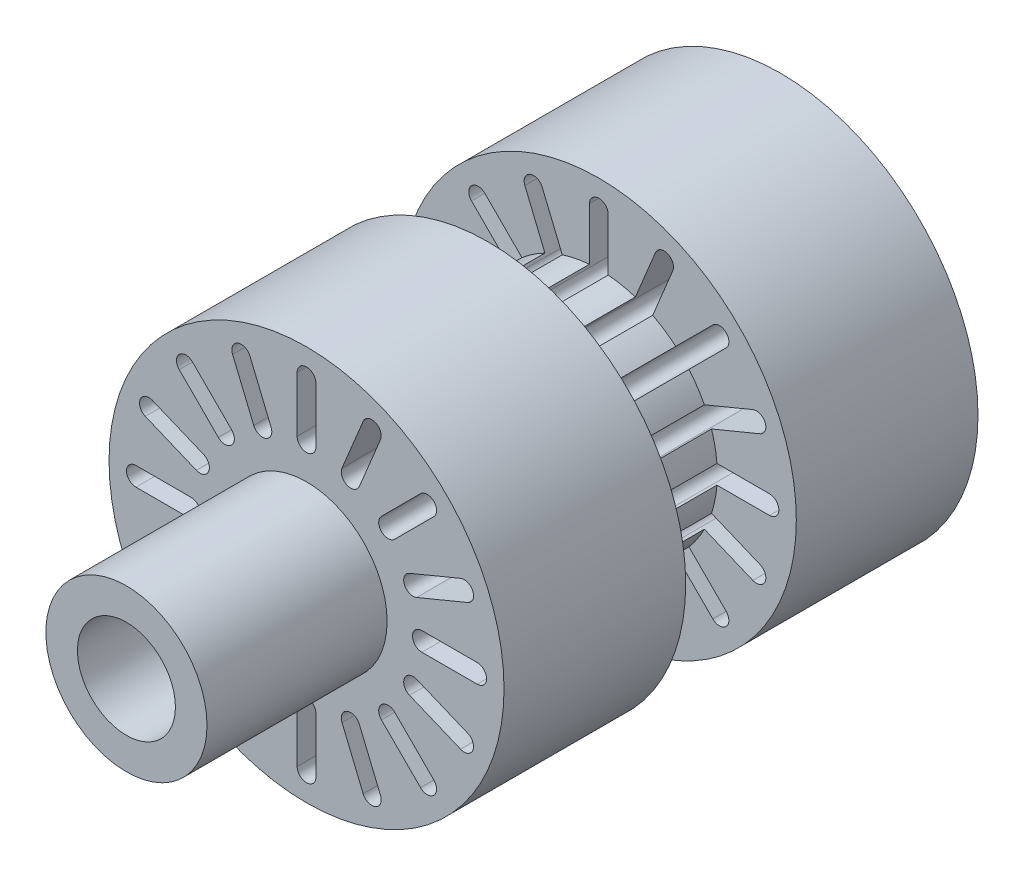
from build123d import *

# Parameters (mm, degrees)
CUT_EXTRUDE1_DEPTH = 86


with BuildPart() as part:
    # Sketch1 → Revolve1 (revolve)
    with BuildSketch(Plane(origin=(0, 0, 0), x_dir=(0, 0, -1), z_dir=(1, 0, 0))):
        Polygon((-15, 0), (15, 0), (3.6, 0), align=None)
        Polygon((-15, 5.1), (-15, 12.5), (-3.5, 12.5), (-3.5, 7.5), (3.5, 7.5), (3.5, 12.5), (15, 12.5), (15, 6), (3.6, 6), (3.6, 3.1), (-15, 3.1), (-26.4, 3.1), (-26.4, 5.1), align=None)
    revolve(axis=Axis((0, 0, 15), (0, 0, -1)))

    # Sketch2 → Cut-Extrude1 (cut)
    with BuildSketch(Plane(origin=(0, 0, -15), x_dir=(-1, 0, 0), z_dir=(0, 0, -1))):
        with BuildLine():
            Line((0.59414275, 10.8), (0.59414275, 7.3))
            ThreePointArc((0.59414275, 7.3), (0, 6.70585725), (-0.59414275, 7.3))
            Line((-0.59414275, 7.3), (-0.59414275, 10.8))
            ThreePointArc((-0.59414275, 10.8), (0, 11.39414275), (0.59414275, 10.8))
        make_face()
        with BuildLine():
            Line((3.584064744, 10.205267538), (2.24467273, 6.971689174))
            ThreePointArc((2.24467273, 6.971689174), (2.566220469, 6.195404261), (3.342505382, 6.516952001))
            Line((3.342505382, 6.516952001), (4.681897395, 9.750530364))
            ThreePointArc((4.681897395, 9.750530364), (4.360349656, 10.526815277), (3.584064744, 10.205267538))
        make_face()
        with BuildLine():
            Line((7.216630869, 8.056875604), (4.741757135, 5.58200187))
            ThreePointArc((4.741757135, 5.58200187), (4.741757135, 4.741757135), (5.58200187, 4.741757135))
            Line((5.58200187, 4.741757135), (8.056875604, 7.216630869))
            ThreePointArc((8.056875604, 7.216630869), (8.056875604, 8.056875604), (7.216630869, 8.056875604))
        make_face()
        with BuildLine():
            Line((9.750530364, 4.681897395), (6.516952001, 3.342505382))
            ThreePointArc((6.516952001, 3.342505382), (6.195404261, 2.566220469), (6.971689174, 2.24467273))
            Line((6.971689174, 2.24467273), (10.205267538, 3.584064744))
            ThreePointArc((10.205267538, 3.584064744), (10.526815277, 4.360349656), (9.750530364, 4.681897395))
        make_face()
        with BuildLine():
            Line((10.8, 0.59414275), (7.3, 0.59414275))
            ThreePointArc((7.3, 0.59414275), (6.70585725, 0), (7.3, -0.59414275))
            Line((7.3, -0.59414275), (10.8, -0.59414275))
            ThreePointArc((10.8, -0.59414275), (11.39414275, 0), (10.8, 0.59414275))
        make_face()
        with BuildLine():
            Line((10.205267538, -3.584064744), (6.971689174, -2.24467273))
            ThreePointArc((6.971689174, -2.24467273), (6.195404261, -2.566220469), (6.516952001, -3.342505382))
            Line((6.516952001, -3.342505382), (9.750530364, -4.681897395))
            ThreePointArc((9.750530364, -4.681897395), (10.526815277, -4.360349656), (10.205267538, -3.584064744))
        make_face()
        with BuildLine():
            Line((8.056875604, -7.216630869), (5.58200187, -4.741757135))
            ThreePointArc((5.58200187, -4.741757135), (4.741757135, -4.741757135), (4.741757135, -5.58200187))
            Line((4.741757135, -5.58200187), (7.216630869, -8.056875604))
            ThreePointArc((7.216630869, -8.056875604), (8.056875604, -8.056875604), (8.056875604, -7.216630869))
        make_face()
        with BuildLine():
            Line((4.681897395, -9.750530364), (3.342505382, -6.516952001))
            ThreePointArc((3.342505382, -6.516952001), (2.566220469, -6.195404261), (2.24467273, -6.971689174))
            Line((2.24467273, -6.971689174), (3.584064744, -10.205267538))
            ThreePointArc((3.584064744, -10.205267538), (4.360349656, -10.526815277), (4.681897395, -9.750530364))
        make_face()
        with BuildLine():
            Line((0.59414275, -10.8), (0.59414275, -7.3))
            ThreePointArc((0.59414275, -7.3), (0, -6.70585725), (-0.59414275, -7.3))
            Line((-0.59414275, -7.3), (-0.59414275, -10.8))
            ThreePointArc((-0.59414275, -10.8), (0, -11.39414275), (0.59414275, -10.8))
        make_face()
        with BuildLine():
            Line((-3.584064744, -10.205267538), (-2.24467273, -6.971689174))
            ThreePointArc((-2.24467273, -6.971689174), (-2.566220469, -6.195404261), (-3.342505382, -6.516952001))
            Line((-3.342505382, -6.516952001), (-4.681897395, -9.750530364))
            ThreePointArc((-4.681897395, -9.750530364), (-4.360349656, -10.526815277), (-3.584064744, -10.205267538))
        make_face()
        with BuildLine():
            Line((-7.216630869, -8.056875604), (-4.741757135, -5.58200187))
            ThreePointArc((-4.741757135, -5.58200187), (-4.741757135, -4.741757135), (-5.58200187, -4.741757135))
            Line((-5.58200187, -4.741757135), (-8.056875604, -7.216630869))
            ThreePointArc((-8.056875604, -7.216630869), (-8.056875604, -8.056875604), (-7.216630869, -8.056875604))
        make_face()
        with BuildLine():
            Line((-9.750530364, -4.681897395), (-6.516952001, -3.342505382))
            ThreePointArc((-6.516952001, -3.342505382), (-6.195404261, -2.566220469), (-6.971689174, -2.24467273))
            Line((-6.971689174, -2.24467273), (-10.205267538, -3.584064744))
            ThreePointArc((-10.205267538, -3.584064744), (-10.526815277, -4.360349656), (-9.750530364, -4.681897395))
        make_face()
        with BuildLine():
            Line((-10.8, -0.59414275), (-7.3, -0.59414275))
            ThreePointArc((-7.3, -0.59414275), (-6.70585725, 0), (-7.3, 0.59414275))
            Line((-7.3, 0.59414275), (-10.8, 0.59414275))
            ThreePointArc((-10.8, 0.59414275), (-11.39414275, 0), (-10.8, -0.59414275))
        make_face()
        with BuildLine():
            Line((-10.205267538, 3.584064744), (-6.971689174, 2.24467273))
            ThreePointArc((-6.971689174, 2.24467273), (-6.195404261, 2.566220469), (-6.516952001, 3.342505382))
            Line((-6.516952001, 3.342505382), (-9.750530364, 4.681897395))
            ThreePointArc((-9.750530364, 4.681897395), (-10.526815277, 4.360349656), (-10.205267538, 3.584064744))
        make_face()
        with BuildLine():
            Line((-8.056875604, 7.216630869), (-5.58200187, 4.741757135))
            ThreePointArc((-5.58200187, 4.741757135), (-4.741757135, 4.741757135), (-4.741757135, 5.58200187))
            Line((-4.741757135, 5.58200187), (-7.216630869, 8.056875604))
            ThreePointArc((-7.216630869, 8.056875604), (-8.056875604, 8.056875604), (-8.056875604, 7.216630869))
        make_face()
        with BuildLine():
            Line((-4.681897395, 9.750530364), (-3.342505382, 6.516952001))
            ThreePointArc((-3.342505382, 6.516952001), (-2.566220469, 6.195404261), (-2.24467273, 6.971689174))
            Line((-2.24467273, 6.971689174), (-3.584064744, 10.205267538))
            ThreePointArc((-3.584064744, 10.205267538), (-4.360349656, 10.526815277), (-4.681897395, 9.750530364))
        make_face()
    extrude(amount=-CUT_EXTRUDE1_DEPTH, mode=Mode.SUBTRACT)


solid = part.part
